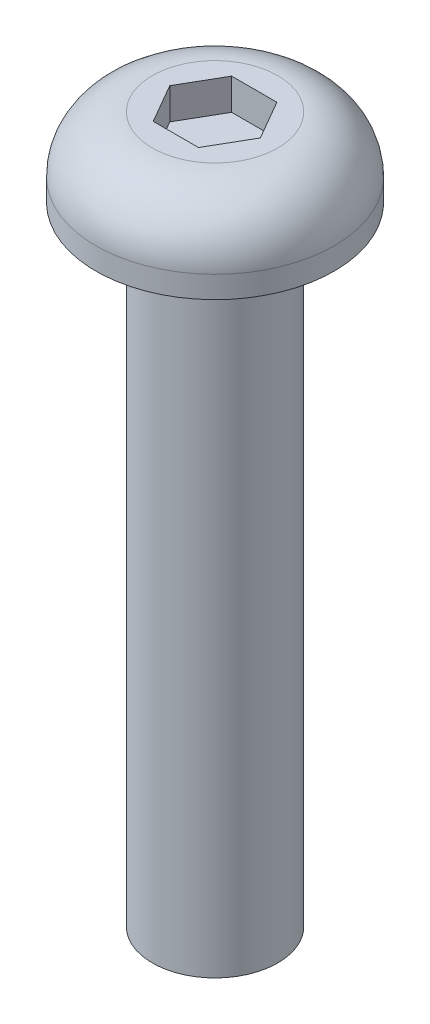
from build123d import *

# Parameters (mm, degrees)
CUT_EXTRUDE1_DEPTH = 1


with BuildPart() as part:
    # Sketch1 → Revolve1 (revolve)
    with BuildSketch(Plane.XY):
        with BuildLine():
            Line((2, 0), (3.8, 0))
            Line((3.8, 0), (3.8, 0.7))
            ThreePointArc((3.8, 0.7), (3.272792206, 1.972792206), (2, 2.5))
            Line((2, 2.5), (0, 2.5))
            Line((0, 2.5), (0, -20))
            Line((0, -20), (2, -20))
            Line((2, -20), (2, 0))
        make_face()
    revolve(axis=Axis((0, -20, 0), (0, 1, 0)))

    # Sketch2 → Cut-Extrude1 (cut)
    with BuildSketch(Plane(origin=(0, 2.5, 0), x_dir=(1, 0, 0), z_dir=(0, 1, 0))):
        Polygon((0.721687836, 1.25), (-0.721687836, 1.25), (-1.443375673, 0), (-0.721687836, -1.25), (0.721687836, -1.25), (1.443375673, 0), align=None)
    extrude(amount=-CUT_EXTRUDE1_DEPTH, mode=Mode.SUBTRACT)


solid = part.part
